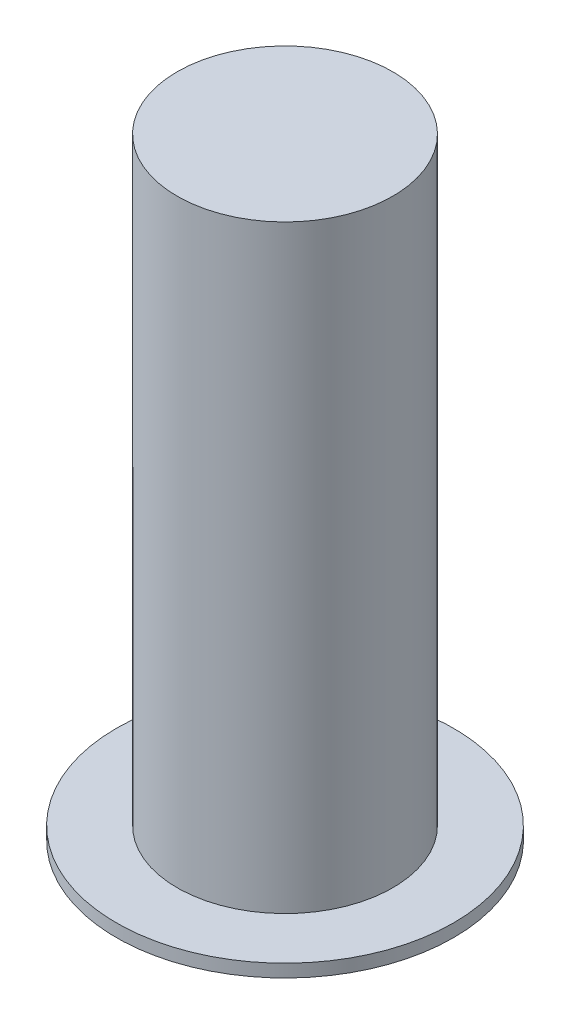
from build123d import *


with BuildPart() as part:
    # Sketch1 → Revolve1 (revolve)
    with BuildSketch(Plane.XY):
        Polygon((-8.545, 0), (-5.465, 0), (-5.465, 30.36), (0, 30.36), (0, 16.55), (-5.135, 16.55), (-5.135, -0.65), (-8.545, -0.65), align=None)
    revolve(axis=Axis((0, 30.36, 0), (0, -1, 0)))


solid = part.part
